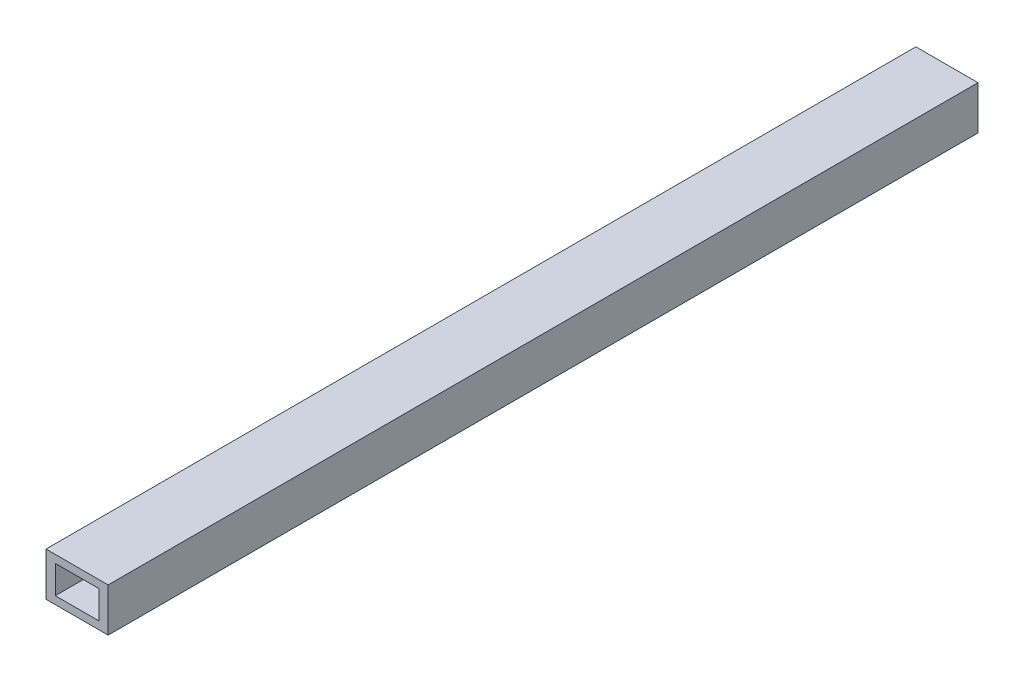
from build123d import *

# Parameters (mm, degrees)
SKETCH1_W           = 10
SKETCH1_H           = 7.004830918
SKETCH1_W_2         = 7
SKETCH1_H_2         = 4.504830918
BOSS_EXTRUDE1_DEPTH = 140


with BuildPart() as part:
    # Sketch1 → Boss-Extrude1 (new body)
    with BuildSketch(Plane.XY):
        Rectangle(SKETCH1_W, SKETCH1_H)
        Rectangle(SKETCH1_W_2, SKETCH1_H_2, mode=Mode.SUBTRACT)
    extrude(amount=-BOSS_EXTRUDE1_DEPTH)


solid = part.part
